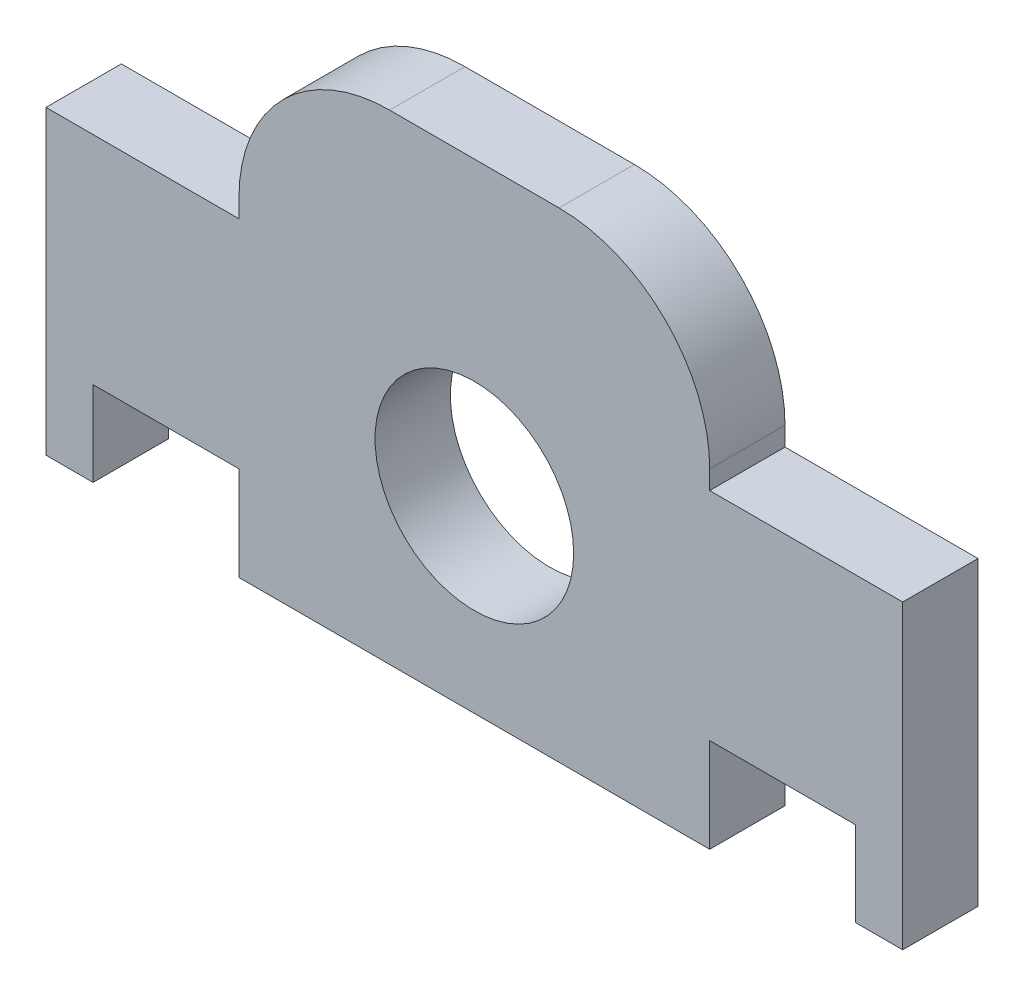
from build123d import *

# Parameters (mm, degrees)
BOSS_EXTRUDE1_DEPTH = 8
SKETCH3_W           = 10
SKETCH3_H           = 10
CUT_EXTRUDE1_DEPTH  = 53.436444721
SKETCH5_W           = 5.5
SKETCH5_H           = 8
BOSS_EXTRUDE2_DEPTH = 23
SKETCH5_3_W         = 5
SKETCH5_3_H         = 8
BOSS_EXTRUDE3_DEPTH = 32
SKETCH5_5_W         = 5
SKETCH5_5_H         = 8
BOSS_EXTRUDE4_DEPTH = 32
SKETCH5_6_W         = 5.5
SKETCH5_6_H         = 8
BOSS_EXTRUDE5_DEPTH = 23


with BuildPart() as part:
    # Sketch2 → Boss-Extrude1 (new body)
    with BuildSketch(Plane.XY):
        Polygon((36.074313409, 13.794830372), (-33.925686591, 13.794830372), (-33.925686591, -37.205169628), (1.074313409, -37.205169628), (36.074313409, -37.205169628), align=None)
        with BuildLine():
            ThreePointArc((11.624313409, -17.205169628), (8.53428995, -24.66514617), (1.074313409, -27.755169628))
            ThreePointArc((1.074313409, -27.755169628), (-6.385663133, -9.745193087), (11.624313409, -17.205169628))
        make_face(mode=Mode.SUBTRACT)
    extrude(amount=BOSS_EXTRUDE1_DEPTH)

    # Sketch3 → Cut-Extrude1 (cut, through all)
    with BuildSketch(Plane.XY.offset(8)):
        with Locations((31.074313409, -32.205169628)):
            Rectangle(SKETCH3_W, SKETCH3_H)
        with Locations((-28.925686591, -32.205169628)):
            Rectangle(SKETCH3_W, SKETCH3_H)
        with BuildLine():
            ThreePointArc((-23.925686591, -2.205169628), (-19.23939509, 9.108538871), (-7.925686591, 13.794830372))
            Line((-7.925686591, 13.794830372), (-33.925686591, 13.794830372))
            Line((-33.925686591, 13.794830372), (-33.925686591, -4.205169628))
            Line((-33.925686591, -4.205169628), (-23.925686591, -4.205169628))
            Line((-23.925686591, -4.205169628), (-23.925686591, -2.205169628))
        make_face()
        with BuildLine():
            Line((26.074313409, -4.205169628), (36.074313409, -4.205169628))
            Line((36.074313409, -4.205169628), (36.074313409, 13.794830372))
            Line((36.074313409, 13.794830372), (10.074313409, 13.794830372))
            ThreePointArc((10.074313409, 13.794830372), (21.388021908, 9.108538871), (26.074313409, -2.205169628))
            Line((26.074313409, -2.205169628), (26.074313409, -4.205169628))
        make_face()
    extrude(amount=-CUT_EXTRUDE1_DEPTH, mode=Mode.SUBTRACT)

    # Sketch5 → Boss-Extrude2 (add)
    with BuildSketch(Plane(origin=(0, -4.205169628, 0), x_dir=(1, 0, 0), z_dir=(0, 1, 0))):
        with Locations((-36.675686591, -4)):
            Rectangle(SKETCH5_W, SKETCH5_H)
    extrude(amount=-BOSS_EXTRUDE2_DEPTH)

    # Sketch5_3 → Boss-Extrude3 (add)
    with BuildSketch(Plane(origin=(0, -4.205169628, 0), x_dir=(1, 0, 0), z_dir=(0, 1, 0))):
        with Locations((-41.925686591, -4)):
            Rectangle(SKETCH5_3_W, SKETCH5_3_H)
    extrude(amount=-BOSS_EXTRUDE3_DEPTH)



with BuildPart() as body_2:
    # Sketch5_5 → Boss-Extrude4 (new body)
    with BuildSketch(Plane(origin=(0, -4.205169628, 0), x_dir=(1, 0, 0), z_dir=(0, 1, 0))):
        with Locations((44.074313409, -4)):
            Rectangle(SKETCH5_5_W, SKETCH5_5_H)
    extrude(amount=-BOSS_EXTRUDE4_DEPTH)


with BuildPart() as part_1:
    add(part.part)

    add(body_2.part)  # Boss-Extrude5 merges body 2
    # Sketch5_6 → Boss-Extrude5 (add)
    with BuildSketch(Plane(origin=(0, -4.205169628, 0), x_dir=(1, 0, 0), z_dir=(0, 1, 0))):
        with Locations((38.824313409, -4)):
            Rectangle(SKETCH5_6_W, SKETCH5_6_H)
    extrude(amount=-BOSS_EXTRUDE5_DEPTH)


solid = part_1.part
